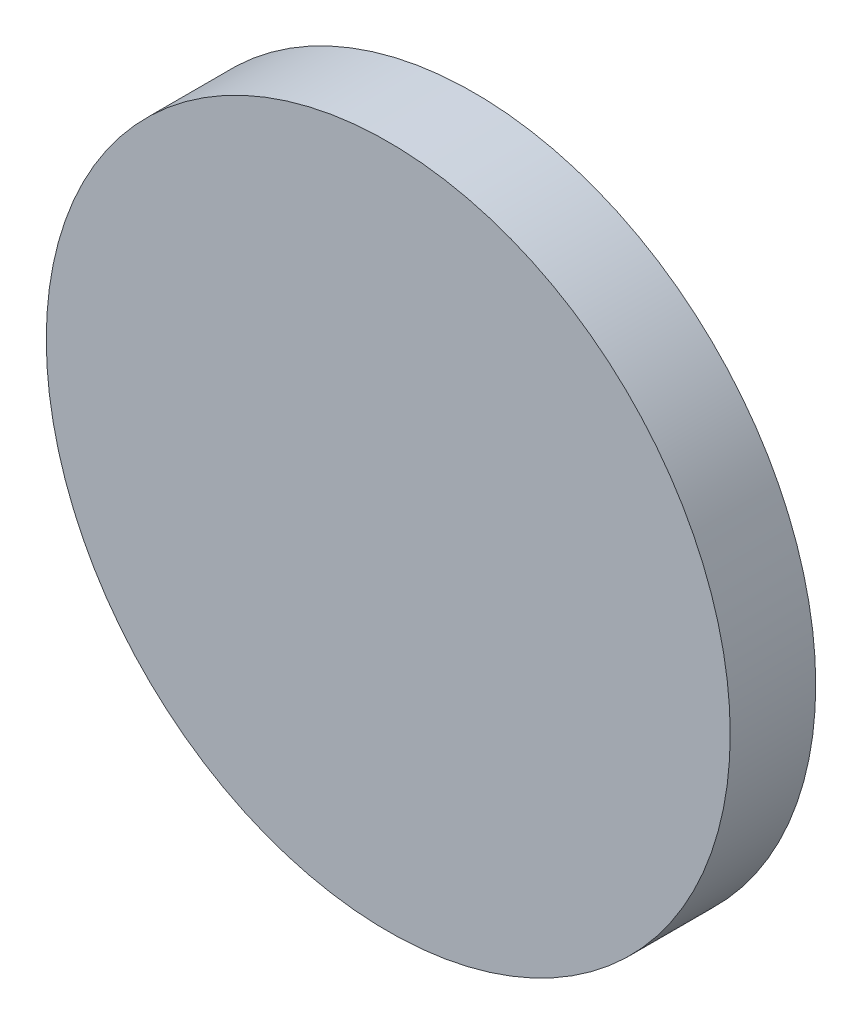
from build123d import *

# Parameters (mm, degrees)
SKETCH1_R           = 14
BOSS_EXTRUDE1_DEPTH = 3.5


with BuildPart() as part:
    # Sketch1 → Boss-Extrude1 (new body)
    with BuildSketch(Plane.XY):
        Circle(SKETCH1_R)
    extrude(amount=BOSS_EXTRUDE1_DEPTH)


solid = part.part
